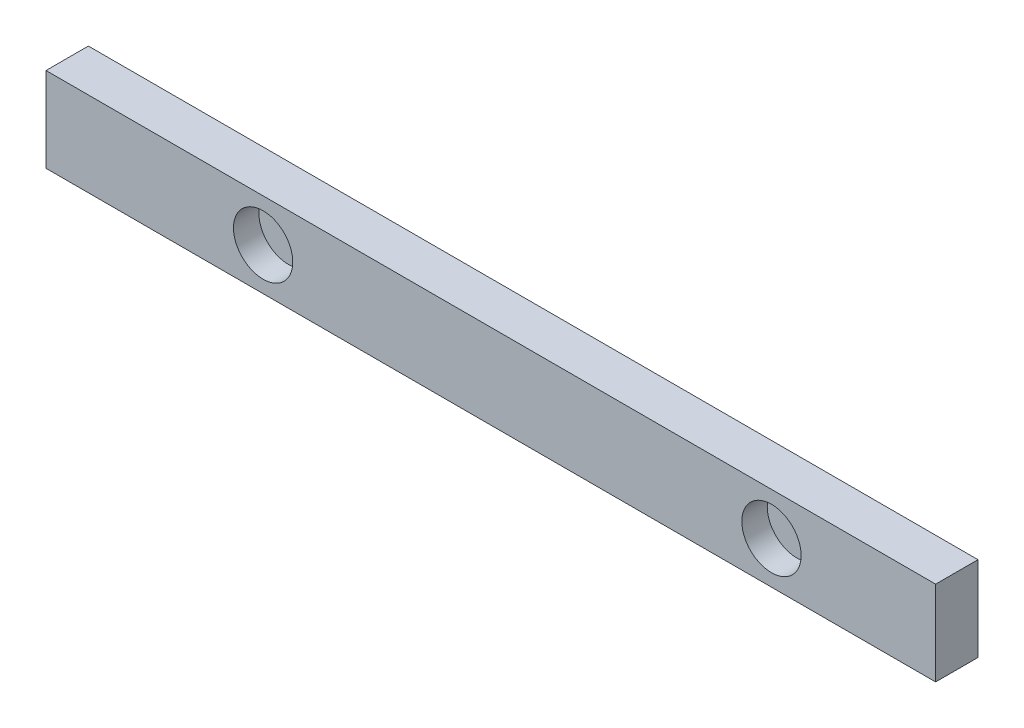
from build123d import *

# Parameters (mm, degrees)
SKETCH1_W           = 533.4
SKETCH1_H           = 50.8
BOSS_EXTRUDE1_DEPTH = 25.4
CUT_EXTRUDE1_START  = -10.16
SKETCH3_R           = 17.78
CUT_EXTRUDE1_DEPTH  = 127
SKETCH4_R           = 6.0198
SKETCH4_R_2         = 2.4638
CUT_EXTRUDE2_DEPTH  = 7.62


with BuildPart() as part:
    # Sketch1 → Boss-Extrude1 (new body)
    with BuildSketch(Plane.XY):
        with Locations((266.7, 25.4)):
            Rectangle(SKETCH1_W, SKETCH1_H)
    extrude(amount=BOSS_EXTRUDE1_DEPTH)

    # Sketch3 → Cut-Extrude1 (cut)
    with BuildSketch(Plane(origin=(0, 0, 0), x_dir=(-1, 0, 0), z_dir=(0, 0, -1)).offset(CUT_EXTRUDE1_START)):
        with Locations((-130.175, 25.290721308)):
            Circle(SKETCH3_R)
        with Locations((-434.975, 25.290721308)):
            Circle(SKETCH3_R)
    extrude(amount=-CUT_EXTRUDE1_DEPTH, mode=Mode.SUBTRACT)

    # Sketch4 → Cut-Extrude2 (cut)
    with BuildSketch(Plane(origin=(0, 0, 0), x_dir=(-1, 0, 0), z_dir=(0, 0, -1))):
        with Locations((-130.175, 25.4)):
            Circle(SKETCH4_R)
        with Locations((-122.728486169, 18.909255319)):
            Circle(SKETCH4_R_2)
        with Locations((-122.728486169, 31.890744681)):
            Circle(SKETCH4_R_2)
        with Locations((-137.621513831, 18.909255319)):
            Circle(SKETCH4_R_2)
        with Locations((-137.621513831, 31.890744681)):
            Circle(SKETCH4_R_2)
        with Locations((-434.975, 25.4)):
            Circle(SKETCH4_R)
        with Locations((-427.528486169, 18.909255319)):
            Circle(SKETCH4_R_2)
        with Locations((-427.528486169, 31.890744681)):
            Circle(SKETCH4_R_2)
        with Locations((-442.421513831, 18.909255319)):
            Circle(SKETCH4_R_2)
        with Locations((-442.421513831, 31.890744681)):
            Circle(SKETCH4_R_2)
    extrude(amount=-CUT_EXTRUDE2_DEPTH, mode=Mode.SUBTRACT)


solid = part.part
